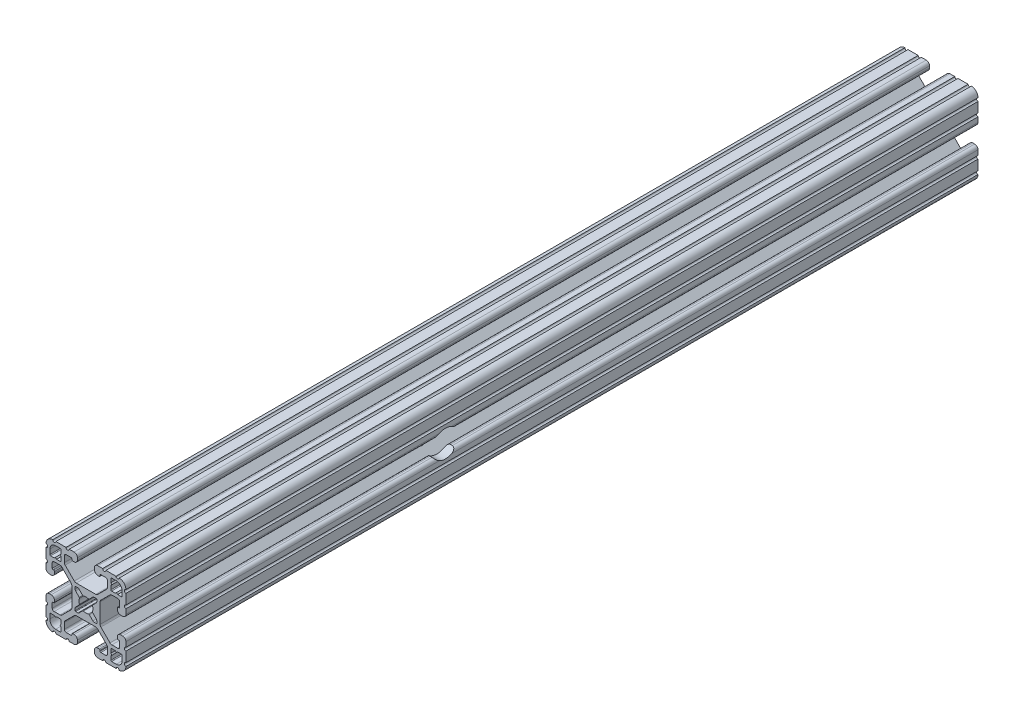
from build123d import *

# Parameters (mm, degrees)
BOSS_EXTRUDE1_DEPTH     = 406.4
SKETCH2_R               = 6.35
CUT_EXTRUDE1_DEPTH      = 1.000000001
CUT_EXTRUDE1_DEPTH_BACK = 39.100000018


with BuildPart() as part:
    # Sketch1 → Boss-Extrude1 (new body)
    with BuildSketch(Plane(origin=(0, 0, -2322.576), x_dir=(-1, 0, 0), z_dir=(0, 0, -1))):
        with BuildLine():
            Line((19.05, -14.325600033), (19.05, -9.4996))
            ThreePointArc((19.05, -9.4996), (18.288, -8.7376), (19.05, -7.9756))
            Line((19.05, -7.9756), (19.05, -5.6388))
            ThreePointArc((19.05, -5.6388), (18.588751759, -4.525248241), (17.4752, -4.064))
            Line((17.4752, -4.064), (16.5608, -4.064))
            ThreePointArc((16.5608, -4.064), (15.447248241, -4.525248241), (14.986, -5.6388))
            Line((14.986, -5.6388), (14.986, -6.350014224))
            ThreePointArc((14.986, -6.350014224), (15.097592316, -6.619421908), (15.367, -6.731014224))
            Line((15.367, -6.731014224), (15.6972, -6.731014224))
            ThreePointArc((15.6972, -6.731014224), (15.966607684, -6.84260654), (16.0782, -7.112014224))
            Line((16.0782, -7.112014224), (16.0782, -9.398014224))
            ThreePointArc((16.0782, -9.398014224), (15.817817928, -10.026632152), (15.1892, -10.287014224))
            Line((15.1892, -10.287014224), (12.375630013, -10.287014224))
            ThreePointArc((12.375630013, -10.287014224), (11.889622054, -10.19034123), (11.477604401, -9.915039836))
            Line((11.477604401, -9.915039836), (7.115699788, -5.553135223))
            ThreePointArc((7.115699788, -5.553135223), (6.840398394, -5.14111757), (6.7437254, -4.655109611))
            Line((6.7437254, -4.655109611), (6.7437254, 4.655109611))
            ThreePointArc((6.7437254, 4.655109611), (6.840398394, 5.14111757), (7.115699788, 5.553135223))
            Line((7.115699788, 5.553135223), (11.477604401, 9.915039836))
            ThreePointArc((11.477604401, 9.915039836), (11.889622054, 10.19034123), (12.375630013, 10.287014224))
            Line((12.375630013, 10.287014224), (15.1892, 10.287014224))
            ThreePointArc((15.1892, 10.287014224), (15.817817928, 10.026632152), (16.0782, 9.398014224))
            Line((16.0782, 9.398014224), (16.0782, 7.112014224))
            ThreePointArc((16.0782, 7.112014224), (15.966607684, 6.84260654), (15.6972, 6.731014224))
            Line((15.6972, 6.731014224), (15.367, 6.731014224))
            ThreePointArc((15.367, 6.731014224), (15.097592316, 6.619421908), (14.986, 6.350014224))
            Line((14.986, 6.350014224), (14.986, 5.6388))
            ThreePointArc((14.986, 5.6388), (15.447248241, 4.525248241), (16.5608, 4.064))
            Line((16.5608, 4.064), (17.4752, 4.064))
            ThreePointArc((17.4752, 4.064), (18.588751759, 4.525248241), (19.05, 5.6388))
            Line((19.05, 5.6388), (19.05, 7.9756))
            ThreePointArc((19.05, 7.9756), (18.288, 8.7376), (19.05, 9.4996))
            Line((19.05, 9.4996), (19.05, 14.325599984))
            ThreePointArc((19.05, 14.325599984), (18.287999986, 15.087549208), (19.049898416, 15.849600009))
            ThreePointArc((19.049898416, 15.849600009), (18.120064036, 18.120064058), (15.849599977, 19.049898414))
            ThreePointArc((15.849599977, 19.049898414), (15.0875492, 18.288000035), (14.325600017, 19.050000016))
            Line((14.325600017, 19.050000016), (9.499600001, 19.050000016))
            ThreePointArc((9.499600001, 19.050000016), (8.737600001, 18.288000016), (7.975600001, 19.050000016))
            Line((7.975600001, 19.050000016), (5.638800016, 19.050000016))
            ThreePointArc((5.638800016, 19.050000016), (4.525248257, 18.588751775), (4.064000016, 17.475200016))
            Line((4.064000016, 17.475200016), (4.064000016, 16.5608))
            ThreePointArc((4.064000016, 16.5608), (4.525248257, 15.447248241), (5.638800016, 14.986))
            Line((5.638800016, 14.986), (6.350014224, 14.986))
            ThreePointArc((6.350014224, 14.986), (6.619421908, 15.097592316), (6.731014224, 15.367))
            Line((6.731014224, 15.367), (6.731014224, 15.6972))
            ThreePointArc((6.731014224, 15.6972), (6.84260654, 15.966607684), (7.112014224, 16.0782))
            Line((7.112014224, 16.0782), (9.398014224, 16.0782))
            ThreePointArc((9.398014224, 16.0782), (10.026632152, 15.817817928), (10.287014224, 15.1892))
            Line((10.287014224, 15.1892), (10.287014224, 12.375630013))
            ThreePointArc((10.287014224, 12.375630013), (10.19034123, 11.889622054), (9.915039836, 11.477604401))
            Line((9.915039836, 11.477604401), (5.553135223, 7.115699788))
            ThreePointArc((5.553135223, 7.115699788), (5.14111757, 6.840398394), (4.655109611, 6.7437254))
            Line((4.655109611, 6.7437254), (-4.655109611, 6.7437254))
            ThreePointArc((-4.655109611, 6.7437254), (-5.14111757, 6.840398394), (-5.553135223, 7.115699788))
            Line((-5.553135223, 7.115699788), (-9.915039836, 11.477604401))
            ThreePointArc((-9.915039836, 11.477604401), (-10.19034123, 11.889622054), (-10.287014224, 12.375630013))
            Line((-10.287014224, 12.375630013), (-10.287014224, 15.1892))
            ThreePointArc((-10.287014224, 15.1892), (-10.026632152, 15.817817928), (-9.398014224, 16.0782))
            Line((-9.398014224, 16.0782), (-7.112014224, 16.0782))
            ThreePointArc((-7.112014224, 16.0782), (-6.84260654, 15.966607684), (-6.731014224, 15.6972))
            Line((-6.731014224, 15.6972), (-6.731014224, 15.367))
            ThreePointArc((-6.731014224, 15.367), (-6.619421908, 15.097592316), (-6.350014224, 14.986))
            Line((-6.350014224, 14.986), (-5.638799984, 14.986))
            ThreePointArc((-5.638799984, 14.986), (-4.525248225, 15.447248241), (-4.063999984, 16.5608))
            Line((-4.063999984, 16.5608), (-4.063999984, 17.475200016))
            ThreePointArc((-4.063999984, 17.475200016), (-4.525248225, 18.588751775), (-5.638799984, 19.050000016))
            Line((-5.638799984, 19.050000016), (-7.975599999, 19.050000016))
            ThreePointArc((-7.975599999, 19.050000016), (-8.737599999, 18.288000016), (-9.499599999, 19.050000016))
            Line((-9.499599999, 19.050000016), (-14.325599999, 19.050000016))
            ThreePointArc((-14.325599999, 19.050000016), (-15.087549199, 18.288000018), (-15.849599993, 19.049898416))
            ThreePointArc((-15.849599993, 19.049898416), (-18.120064042, 18.120064036), (-19.049898398, 15.849599976))
            ThreePointArc((-19.049898398, 15.849599976), (-18.288000019, 15.087549199), (-19.05, 14.325600017))
            Line((-19.05, 14.325600017), (-19.05, 9.4996))
            ThreePointArc((-19.05, 9.4996), (-18.288, 8.7376), (-19.05, 7.9756))
            Line((-19.05, 7.9756), (-19.05, 5.6388))
            ThreePointArc((-19.05, 5.6388), (-18.588751759, 4.525248241), (-17.4752, 4.064))
            Line((-17.4752, 4.064), (-16.5608, 4.064))
            ThreePointArc((-16.5608, 4.064), (-15.447248241, 4.525248241), (-14.986, 5.6388))
            Line((-14.986, 5.6388), (-14.986, 6.350014224))
            ThreePointArc((-14.986, 6.350014224), (-15.097592316, 6.619421908), (-15.367, 6.731014224))
            Line((-15.367, 6.731014224), (-15.6972, 6.731014224))
            ThreePointArc((-15.6972, 6.731014224), (-15.966607684, 6.84260654), (-16.0782, 7.112014224))
            Line((-16.0782, 7.112014224), (-16.0782, 9.398014224))
            ThreePointArc((-16.0782, 9.398014224), (-15.817817928, 10.026632152), (-15.1892, 10.287014224))
            Line((-15.1892, 10.287014224), (-12.375630013, 10.287014224))
            ThreePointArc((-12.375630013, 10.287014224), (-11.889622054, 10.19034123), (-11.477604401, 9.915039836))
            Line((-11.477604401, 9.915039836), (-7.115699788, 5.553135223))
            ThreePointArc((-7.115699788, 5.553135223), (-6.840398394, 5.14111757), (-6.7437254, 4.655109611))
            Line((-6.7437254, 4.655109611), (-6.7437254, -4.655109611))
            ThreePointArc((-6.7437254, -4.655109611), (-6.840398394, -5.14111757), (-7.115699788, -5.553135223))
            Line((-7.115699788, -5.553135223), (-11.477604401, -9.915039836))
            ThreePointArc((-11.477604401, -9.915039836), (-11.889622054, -10.19034123), (-12.375630013, -10.287014224))
            Line((-12.375630013, -10.287014224), (-15.1892, -10.287014224))
            ThreePointArc((-15.1892, -10.287014224), (-15.817817928, -10.026632152), (-16.0782, -9.398014224))
            Line((-16.0782, -9.398014224), (-16.0782, -7.112014224))
            ThreePointArc((-16.0782, -7.112014224), (-15.966607684, -6.84260654), (-15.6972, -6.731014224))
            Line((-15.6972, -6.731014224), (-15.367, -6.731014224))
            ThreePointArc((-15.367, -6.731014224), (-15.097592316, -6.619421908), (-14.986, -6.350014224))
            Line((-14.986, -6.350014224), (-14.986, -5.6388))
            ThreePointArc((-14.986, -5.6388), (-15.447248241, -4.525248241), (-16.5608, -4.064))
            Line((-16.5608, -4.064), (-17.4752, -4.064))
            ThreePointArc((-17.4752, -4.064), (-18.588751759, -4.525248241), (-19.05, -5.6388))
            Line((-19.05, -5.6388), (-19.05, -7.9756))
            ThreePointArc((-19.05, -7.9756), (-18.288, -8.7376), (-19.05, -9.4996))
            Line((-19.05, -9.4996), (-19.05, -14.3256))
            ThreePointArc((-19.05, -14.3256), (-18.288000002, -15.0875492), (-19.0498984, -15.849599993))
            ThreePointArc((-19.0498984, -15.849599993), (-18.120064019, -18.120064043), (-15.84959996, -19.049898399))
            ThreePointArc((-15.84959996, -19.049898399), (-15.087549183, -18.288000019), (-14.325600001, -19.050000001))
            Line((-14.325600001, -19.050000001), (-9.499599984, -19.050000001))
            ThreePointArc((-9.499599984, -19.050000001), (-8.737599984, -18.288000001), (-7.975599984, -19.050000001))
            Line((-7.975599984, -19.050000001), (-5.638799984, -19.050000001))
            ThreePointArc((-5.638799984, -19.050000001), (-4.525248225, -18.58875176), (-4.063999984, -17.475200001))
            Line((-4.063999984, -17.475200001), (-4.063999984, -16.5608))
            ThreePointArc((-4.063999984, -16.5608), (-4.525248225, -15.447248241), (-5.638799984, -14.986))
            Line((-5.638799984, -14.986), (-6.350014224, -14.986))
            ThreePointArc((-6.350014224, -14.986), (-6.619421908, -15.097592316), (-6.731014224, -15.367))
            Line((-6.731014224, -15.367), (-6.731014224, -15.6972))
            ThreePointArc((-6.731014224, -15.6972), (-6.84260654, -15.966607684), (-7.112014224, -16.0782))
            Line((-7.112014224, -16.0782), (-9.398014224, -16.0782))
            ThreePointArc((-9.398014224, -16.0782), (-10.026632152, -15.817817928), (-10.287014224, -15.1892))
            Line((-10.287014224, -15.1892), (-10.287014224, -12.375630013))
            ThreePointArc((-10.287014224, -12.375630013), (-10.19034123, -11.889622054), (-9.915039836, -11.477604401))
            Line((-9.915039836, -11.477604401), (-5.553135223, -7.115699788))
            ThreePointArc((-5.553135223, -7.115699788), (-5.14111757, -6.840398394), (-4.655109611, -6.7437254))
            Line((-4.655109611, -6.7437254), (4.655109611, -6.7437254))
            ThreePointArc((4.655109611, -6.7437254), (5.14111757, -6.840398394), (5.553135223, -7.115699788))
            Line((5.553135223, -7.115699788), (9.915039836, -11.477604401))
            ThreePointArc((9.915039836, -11.477604401), (10.19034123, -11.889622054), (10.287014224, -12.375630013))
            Line((10.287014224, -12.375630013), (10.287014224, -15.1892))
            ThreePointArc((10.287014224, -15.1892), (10.026632152, -15.817817928), (9.398014224, -16.0782))
            Line((9.398014224, -16.0782), (7.112014224, -16.0782))
            ThreePointArc((7.112014224, -16.0782), (6.84260654, -15.966607684), (6.731014224, -15.6972))
            Line((6.731014224, -15.6972), (6.731014224, -15.367))
            ThreePointArc((6.731014224, -15.367), (6.619421908, -15.097592316), (6.350014224, -14.986))
            Line((6.350014224, -14.986), (5.638800016, -14.986))
            ThreePointArc((5.638800016, -14.986), (4.525248257, -15.447248241), (4.064000016, -16.5608))
            Line((4.064000016, -16.5608), (4.064000016, -17.475200001))
            ThreePointArc((4.064000016, -17.475200001), (4.525248257, -18.58875176), (5.638800016, -19.050000001))
            Line((5.638800016, -19.050000001), (7.975600016, -19.050000001))
            ThreePointArc((7.975600016, -19.050000001), (8.737600016, -18.288000001), (9.499600016, -19.050000001))
            Line((9.499600016, -19.050000001), (14.325600016, -19.050000001))
            ThreePointArc((14.325600016, -19.050000001), (15.087549216, -18.288000002), (15.849600009, -19.0498984))
            ThreePointArc((15.849600009, -19.0498984), (18.120064059, -18.12006402), (19.049898415, -15.849599961))
            ThreePointArc((19.049898415, -15.849599961), (18.288000034, -15.087549207), (19.05, -14.325600033))
        make_face()
        with BuildLine():
            Line((17.246614224, 14.452614224), (17.246614224, 12.242814224))
            ThreePointArc((17.246614224, 12.242814224), (17.135021908, 11.97340654), (16.865614224, 11.861814224))
            Line((16.865614224, 11.861814224), (15.092694224, 11.861814224))
            Line((15.092694224, 11.861814224), (14.554214224, 12.400294224))
            Line((14.554214224, 12.400294224), (14.015734224, 11.861814224))
            Line((14.015734224, 11.861814224), (12.242814224, 11.861814224))
            ThreePointArc((12.242814224, 11.861814224), (11.97340654, 11.97340654), (11.861814224, 12.242814224))
            Line((11.861814224, 12.242814224), (11.861814224, 14.015734224))
            Line((11.861814224, 14.015734224), (12.400294224, 14.554214224))
            Line((12.400294224, 14.554214224), (11.861814224, 15.092694224))
            Line((11.861814224, 15.092694224), (11.861814224, 16.865614224))
            ThreePointArc((11.861814224, 16.865614224), (11.97340654, 17.135021908), (12.242814224, 17.246614224))
            Line((12.242814224, 17.246614224), (14.452614224, 17.246614224))
            ThreePointArc((14.452614224, 17.246614224), (16.428270571, 16.428270571), (17.246614224, 14.452614224))
        make_face(mode=Mode.SUBTRACT)
        with BuildLine():
            Line((17.246614224, -12.242814224), (17.246614224, -14.452614224))
            ThreePointArc((17.246614224, -14.452614224), (16.428270571, -16.428270571), (14.452614224, -17.246614224))
            Line((14.452614224, -17.246614224), (12.242814224, -17.246614224))
            ThreePointArc((12.242814224, -17.246614224), (11.97340654, -17.135021908), (11.861814224, -16.865614224))
            Line((11.861814224, -16.865614224), (11.861814224, -15.092694224))
            Line((11.861814224, -15.092694224), (12.400294224, -14.554214224))
            Line((12.400294224, -14.554214224), (11.861814224, -14.015734224))
            Line((11.861814224, -14.015734224), (11.861814224, -12.242814224))
            ThreePointArc((11.861814224, -12.242814224), (11.97340654, -11.97340654), (12.242814224, -11.861814224))
            Line((12.242814224, -11.861814224), (14.015734224, -11.861814224))
            Line((14.015734224, -11.861814224), (14.554214224, -12.400294224))
            Line((14.554214224, -12.400294224), (15.092694224, -11.861814224))
            Line((15.092694224, -11.861814224), (16.865614224, -11.861814224))
            ThreePointArc((16.865614224, -11.861814224), (17.135021908, -11.97340654), (17.246614224, -12.242814224))
        make_face(mode=Mode.SUBTRACT)
        with BuildLine():
            Line((5.1689, -3.920689755), (5.1689, -4.9149))
            ThreePointArc((5.1689, -4.9149), (5.094505122, -5.094505122), (4.9149, -5.1689))
            Line((4.9149, -5.1689), (3.920689755, -5.1689))
            ThreePointArc((3.920689755, -5.1689), (3.580484184, -5.101228904), (3.292071827, -4.908517928))
            Line((3.292071827, -4.908517928), (1.582347442, -3.198793543))
            ThreePointArc((1.582347442, -3.198793543), (1.393016011, -3.095711236), (1.178048687, -3.111879183))
            ThreePointArc((1.178048687, -3.111879183), (0, -3.3274), (-1.178048687, -3.111879183))
            ThreePointArc((-1.178048687, -3.111879183), (-1.393016011, -3.095711236), (-1.582347442, -3.198793543))
            Line((-1.582347442, -3.198793543), (-3.292071827, -4.908517928))
            ThreePointArc((-3.292071827, -4.908517928), (-3.580484184, -5.101228904), (-3.920689755, -5.1689))
            Line((-3.920689755, -5.1689), (-4.9149, -5.1689))
            ThreePointArc((-4.9149, -5.1689), (-5.094505122, -5.094505122), (-5.1689, -4.9149))
            Line((-5.1689, -4.9149), (-5.1689, -3.920689755))
            ThreePointArc((-5.1689, -3.920689755), (-5.101228904, -3.580484184), (-4.908517928, -3.292071827))
            Line((-4.908517928, -3.292071827), (-3.198793543, -1.582347442))
            ThreePointArc((-3.198793543, -1.582347442), (-3.095711236, -1.393016011), (-3.111879183, -1.178048687))
            ThreePointArc((-3.111879183, -1.178048687), (-3.3274, 0), (-3.111879183, 1.178048687))
            ThreePointArc((-3.111879183, 1.178048687), (-3.095711236, 1.393016011), (-3.198793543, 1.582347442))
            Line((-3.198793543, 1.582347442), (-4.908517928, 3.292071827))
            ThreePointArc((-4.908517928, 3.292071827), (-5.101228904, 3.580484184), (-5.1689, 3.920689755))
            Line((-5.1689, 3.920689755), (-5.1689, 4.9149))
            ThreePointArc((-5.1689, 4.9149), (-5.094505122, 5.094505122), (-4.9149, 5.1689))
            Line((-4.9149, 5.1689), (-3.920689755, 5.1689))
            ThreePointArc((-3.920689755, 5.1689), (-3.580484184, 5.101228904), (-3.292071827, 4.908517928))
            Line((-3.292071827, 4.908517928), (-1.582347442, 3.198793543))
            ThreePointArc((-1.582347442, 3.198793543), (-1.393016011, 3.095711236), (-1.178048687, 3.111879183))
            ThreePointArc((-1.178048687, 3.111879183), (0, 3.3274), (1.178048687, 3.111879183))
            ThreePointArc((1.178048687, 3.111879183), (1.393016011, 3.095711236), (1.582347442, 3.198793543))
            Line((1.582347442, 3.198793543), (3.292071827, 4.908517928))
            ThreePointArc((3.292071827, 4.908517928), (3.580484184, 5.101228904), (3.920689755, 5.1689))
            Line((3.920689755, 5.1689), (4.9149, 5.1689))
            ThreePointArc((4.9149, 5.1689), (5.094505122, 5.094505122), (5.1689, 4.9149))
            Line((5.1689, 4.9149), (5.1689, 3.920689755))
            ThreePointArc((5.1689, 3.920689755), (5.101228904, 3.580484184), (4.908517928, 3.292071827))
            Line((4.908517928, 3.292071827), (3.198793543, 1.582347442))
            ThreePointArc((3.198793543, 1.582347442), (3.095711236, 1.393016011), (3.111879183, 1.178048687))
            ThreePointArc((3.111879183, 1.178048687), (3.3274, 0), (3.111879183, -1.178048687))
            ThreePointArc((3.111879183, -1.178048687), (3.095711236, -1.393016011), (3.198793543, -1.582347442))
            Line((3.198793543, -1.582347442), (4.908517928, -3.292071827))
            ThreePointArc((4.908517928, -3.292071827), (5.101228904, -3.580484184), (5.1689, -3.920689755))
        make_face(mode=Mode.SUBTRACT)
        with BuildLine():
            Line((-11.861814224, -12.242814224), (-11.861814224, -14.015734224))
            Line((-11.861814224, -14.015734224), (-12.400294224, -14.554214224))
            Line((-12.400294224, -14.554214224), (-11.861814224, -15.092694224))
            Line((-11.861814224, -15.092694224), (-11.861814224, -16.865614224))
            ThreePointArc((-11.861814224, -16.865614224), (-11.97340654, -17.135021908), (-12.242814224, -17.246614224))
            Line((-12.242814224, -17.246614224), (-14.452614224, -17.246614224))
            ThreePointArc((-14.452614224, -17.246614224), (-16.428270571, -16.428270571), (-17.246614224, -14.452614224))
            Line((-17.246614224, -14.452614224), (-17.246614224, -12.242814224))
            ThreePointArc((-17.246614224, -12.242814224), (-17.135021908, -11.97340654), (-16.865614224, -11.861814224))
            Line((-16.865614224, -11.861814224), (-15.092694224, -11.861814224))
            Line((-15.092694224, -11.861814224), (-14.554214224, -12.400294224))
            Line((-14.554214224, -12.400294224), (-14.015734224, -11.861814224))
            Line((-14.015734224, -11.861814224), (-12.242814224, -11.861814224))
            ThreePointArc((-12.242814224, -11.861814224), (-11.97340654, -11.97340654), (-11.861814224, -12.242814224))
        make_face(mode=Mode.SUBTRACT)
        with BuildLine():
            Line((-11.861814224, 16.865614224), (-11.861814224, 15.092694224))
            Line((-11.861814224, 15.092694224), (-12.400294224, 14.554214224))
            Line((-12.400294224, 14.554214224), (-11.861814224, 14.015734224))
            Line((-11.861814224, 14.015734224), (-11.861814224, 12.242814224))
            ThreePointArc((-11.861814224, 12.242814224), (-11.97340654, 11.97340654), (-12.242814224, 11.861814224))
            Line((-12.242814224, 11.861814224), (-14.015734224, 11.861814224))
            Line((-14.015734224, 11.861814224), (-14.554214224, 12.400294224))
            Line((-14.554214224, 12.400294224), (-15.092694224, 11.861814224))
            Line((-15.092694224, 11.861814224), (-16.865614224, 11.861814224))
            ThreePointArc((-16.865614224, 11.861814224), (-17.135021908, 11.97340654), (-17.246614224, 12.242814224))
            Line((-17.246614224, 12.242814224), (-17.246614224, 14.452614224))
            ThreePointArc((-17.246614224, 14.452614224), (-16.428270571, 16.428270571), (-14.452614224, 17.246614224))
            Line((-14.452614224, 17.246614224), (-12.242814224, 17.246614224))
            ThreePointArc((-12.242814224, 17.246614224), (-11.97340654, 17.135021908), (-11.861814224, 16.865614224))
        make_face(mode=Mode.SUBTRACT)
    extrude(amount=-BOSS_EXTRUDE1_DEPTH)

    # Sketch2 → Cut-Extrude1 (cut, two sides)
    with BuildSketch(Plane(origin=(19.05, 0, 0), x_dir=(0, 0, -1), z_dir=(1, 0, 0))) as cut_extrude1_sk:
        with Locations((2068.576, 0)):
            Circle(SKETCH2_R)
    extrude(amount=CUT_EXTRUDE1_DEPTH, mode=Mode.SUBTRACT)
    extrude(cut_extrude1_sk.sketch, amount=-CUT_EXTRUDE1_DEPTH_BACK, mode=Mode.SUBTRACT)


solid = part.part
